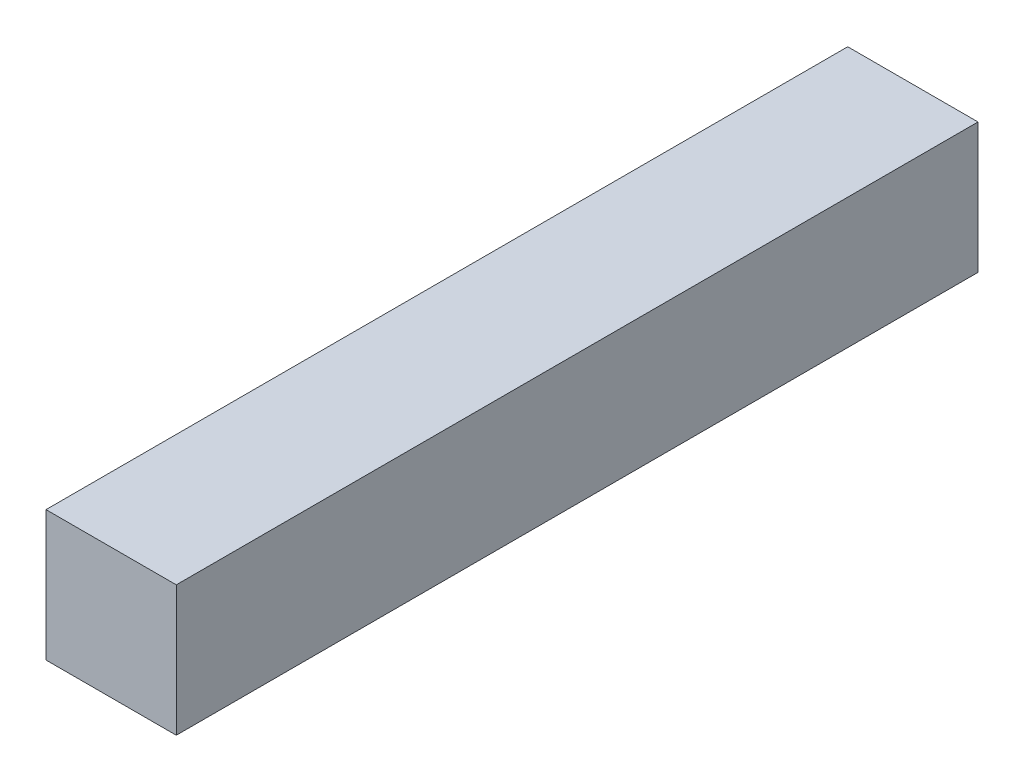
from build123d import *

# Parameters (mm, degrees)
SKETCH1_W           = 65
SKETCH1_H           = 65
BOSS_EXTRUDE1_DEPTH = 400


with BuildPart() as part:
    # Sketch1 → Boss-Extrude1 (new body)
    with BuildSketch(Plane.XY):
        with Locations((32.5, 32.5)):
            Rectangle(SKETCH1_W, SKETCH1_H)
    extrude(amount=BOSS_EXTRUDE1_DEPTH)


solid = part.part
